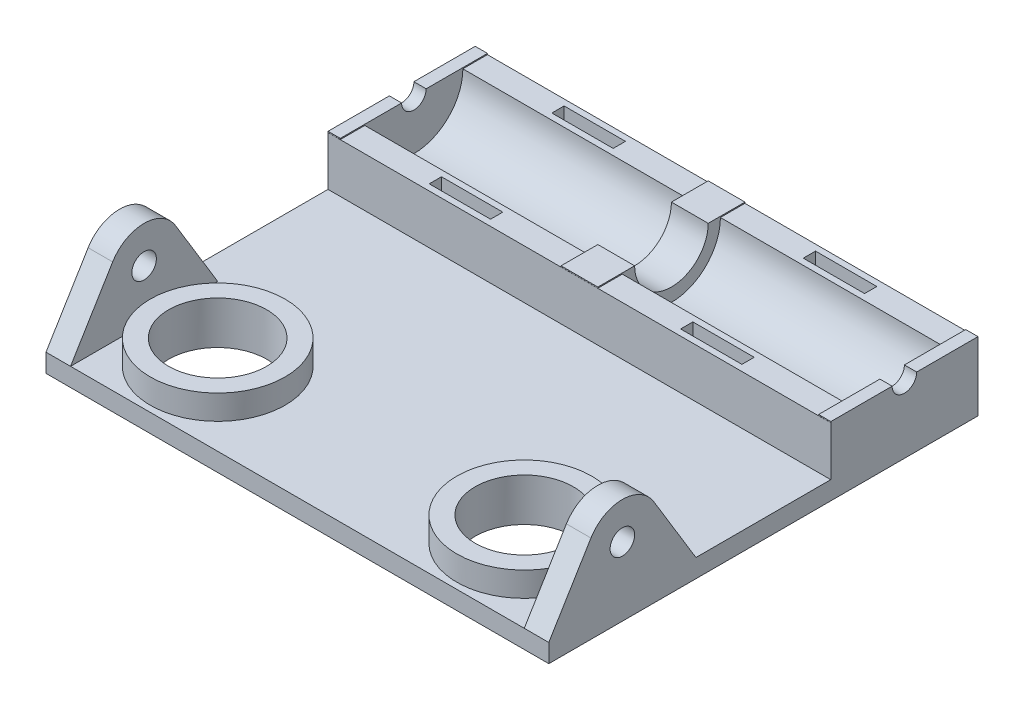
from build123d import *

# Parameters (mm, degrees)
SKETCH1_W           = 41
SKETCH1_H           = 35
BOSS_EXTRUDE1_DEPTH = 1.5
BOSS_EXTRUDE3_DEPTH = 1.5
BOSS_EXTRUDE4_DEPTH = 1
SKETCH5_R           = 1
BOSS_EXTRUDE5_DEPTH = 2
SKETCH6_R           = 4
CUT_EXTRUDE1_DEPTH  = 3
SKETCH7_R           = 5.5
SKETCH7_R_2         = 4
BOSS_EXTRUDE6_DEPTH = 2
BOSS_EXTRUDE7_DEPTH = 20.5
SKETCH8_W           = 5
SKETCH8_H           = 1
CUT_EXTRUDE2_DEPTH  = 2


with BuildPart() as part:
    # Sketch1 → Boss-Extrude1 (new body)
    with BuildSketch(Plane(origin=(0, 0, 0), x_dir=(1, 0, 0), z_dir=(0, 1, 0))):
        Rectangle(SKETCH1_W, SKETCH1_H)
    extrude(amount=BOSS_EXTRUDE1_DEPTH)

    # Sketch4 → Boss-Extrude4 (add)
    with BuildSketch(Plane.ZY.offset(20.5)):
        with BuildLine():
            Line((-10.5, 5.6), (-5.5, 5.6))
            Line((-5.5, 5.6), (-5.5, 1.5))
            Line((-5.5, 1.5), (-17.5, 1.5))
            Line((-17.5, 1.5), (-17.5, 5.6))
            Line((-17.5, 5.6), (-12.5, 5.6))
            ThreePointArc((-12.5, 5.6), (-11.5, 4.6), (-10.5, 5.6))
        make_face()
    boss_extrude4 = extrude(amount=-BOSS_EXTRUDE4_DEPTH)

    # Mirror1: Boss-Extrude4 across plane
    add(boss_extrude4.mirror(Plane(origin=(0, 0, 0), x_dir=(0, 0, 1), z_dir=(1, 0, 0))))

    # Sketch5 → Boss-Extrude5 (add)
    with BuildSketch(Plane.ZY.offset(20.5)):
        with BuildLine():
            Line((8.935852656, 7.157288797), (5.5, 1.5))
            Line((5.5, 1.5), (17.5, 1.5))
            Line((17.5, 1.5), (14.064147344, 7.157288797))
            ThreePointArc((14.064147344, 7.157288797), (11.5, 8.6), (8.935852656, 7.157288797))
        make_face()
        with Locations((11.5, 5.6)):
            Circle(SKETCH5_R, mode=Mode.SUBTRACT)
    boss_extrude5 = extrude(amount=-BOSS_EXTRUDE5_DEPTH)

    # Mirror2: Boss-Extrude5 across plane
    add(boss_extrude5.mirror(Plane(origin=(0, 0, 0), x_dir=(0, 0, 1), z_dir=(1, 0, 0))))

    # Sketch6 → Cut-Extrude1 (cut)
    with BuildSketch(Plane(origin=(0, 1.5, 0), x_dir=(1, 0, 0), z_dir=(0, 1, 0))):
        with Locations((-12.5, -11.5)):
            Circle(SKETCH6_R)
        with Locations((12.5, -11.5)):
            Circle(SKETCH6_R)
    extrude(amount=-CUT_EXTRUDE1_DEPTH, mode=Mode.SUBTRACT)

    # Sketch7 → Boss-Extrude6 (add)
    with BuildSketch(Plane(origin=(0, 1.5, 0), x_dir=(1, 0, 0), z_dir=(0, 1, 0))):
        with Locations((-12.5, -11.5)):
            Circle(SKETCH7_R)
        with Locations((-12.5, -11.5)):
            Circle(SKETCH7_R_2, mode=Mode.SUBTRACT)
        with Locations((12.5, -11.5)):
            Circle(SKETCH7_R)
        with Locations((12.5, -11.5)):
            Circle(SKETCH7_R_2, mode=Mode.SUBTRACT)
    extrude(amount=BOSS_EXTRUDE6_DEPTH)

    # Sketch9 → Boss-Extrude7 (add, symmetric)
    with BuildSketch(Plane(origin=(0, 0, 0), x_dir=(0, 0, -1), z_dir=(1, 0, 0))):
        with BuildLine():
            Line((15.493586506, 5.513707806), (17.493586506, 5.513707806))
            Line((17.493586506, 5.513707806), (17.493586506, 1.413707806))
            Line((17.493586506, 1.413707806), (5.493586506, 1.413707806))
            Line((5.493586506, 1.413707806), (5.493586506, 5.513707806))
            Line((5.493586506, 5.513707806), (7.493586506, 5.513707806))
            ThreePointArc((7.493586506, 5.513707806), (11.493586506, 1.513707806), (15.493586506, 5.513707806))
        make_face()
    extrude(amount=BOSS_EXTRUDE7_DEPTH, both=True)

    # Sketch8 → Cut-Extrude2 (cut)
    with BuildSketch(Plane(origin=(0, 5.6, 0), x_dir=(1, 0, 0), z_dir=(0, 1, 0))):
        with Locations((-10.25, 16.5)):
            Rectangle(SKETCH8_W, SKETCH8_H)
        with Locations((-10.25, 6.5)):
            Rectangle(SKETCH8_W, SKETCH8_H)
        with Locations((10.25, 6.5)):
            Rectangle(SKETCH8_W, SKETCH8_H)
        with Locations((10.25, 16.5)):
            Rectangle(SKETCH8_W, SKETCH8_H)
    extrude(amount=-CUT_EXTRUDE2_DEPTH, mode=Mode.SUBTRACT)


with BuildPart() as body_2:
    # Sketch3 → Boss-Extrude3 (new body, symmetric)
    with BuildSketch(Plane(origin=(0, 0, 0), x_dir=(0, 0, -1), z_dir=(1, 0, 0))):
        with BuildLine():
            Line((5.5, 1.5), (5.5, 5.6))
            Line((5.5, 5.6), (8.5, 5.6))
            ThreePointArc((8.5, 5.6), (11.5, 2.6), (14.5, 5.6))
            Line((14.5, 5.6), (17.5, 5.6))
            Line((17.5, 5.6), (17.5, 1.5))
            Line((17.5, 1.5), (5.5, 1.5))
        make_face()
    extrude(amount=BOSS_EXTRUDE3_DEPTH, both=True)


solid = Compound([part.part, body_2.part])
